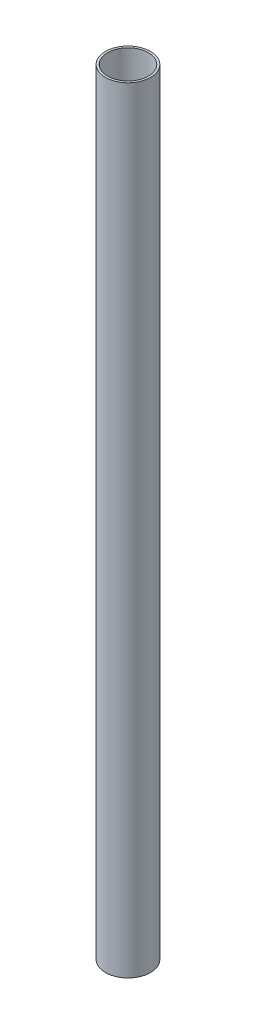
from build123d import *

# Parameters (mm, degrees)
SKETCH1_R           = 15.875
SKETCH1_R_2         = 14.351
BOSS_EXTRUDE1_DEPTH = 546.1


with BuildPart() as part:
    # Sketch1 → Boss-Extrude1 (new body)
    with BuildSketch(Plane(origin=(0, 0, 0), x_dir=(1, 0, 0), z_dir=(0, 1, 0))):
        Circle(SKETCH1_R)
        Circle(SKETCH1_R_2, mode=Mode.SUBTRACT)
    extrude(amount=BOSS_EXTRUDE1_DEPTH)


solid = part.part
